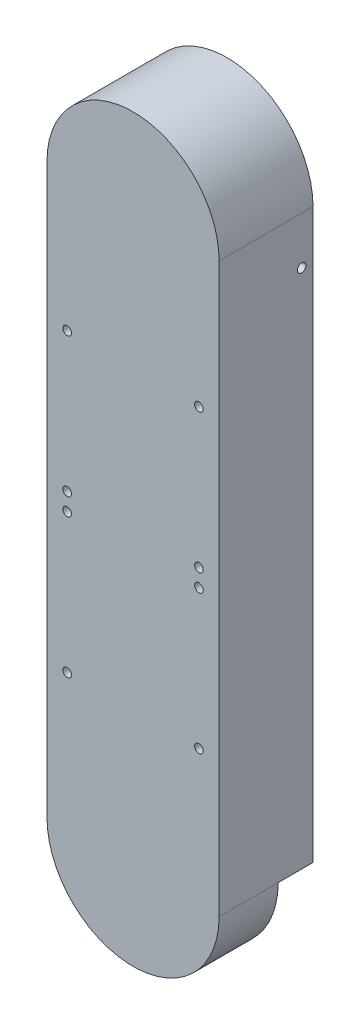
from build123d import *

# Parameters (mm, degrees)
EXTRUDE_1_DEPTH     = 35
EXTRUDE_2_DEPTH     = 3.18
SKETCH_3_R          = 1.75
CUT_EXTRUDE_1_DEPTH = 39.18
SKETCH_4_R          = 1.75
CUT_EXTRUDE_2_DEPTH = 39.18
SKETCH_5_R          = 1.75
CUT_EXTRUDE_3_DEPTH = 71
EXTRUDE_3_DEPTH     = 115.49
EXTRUDE_7_DEPTH     = 24
SKETCH_11_R         = 25
CUT_EXTRUDE_4_DEPTH = 20.82
SKETCH_12_R         = 1.75
CUT_EXTRUDE_5_DEPTH = 39.18
SKETCH_13_R         = 1.75
CUT_EXTRUDE_6_DEPTH = 24


with BuildPart() as part:
    # 草图1 → 凸台-拉伸1 (new body)
    with BuildSketch(Plane.XY):
        with BuildLine():
            Line((-30, 0), (-30, -115.49))
            Line((-30, -115.49), (-35, -115.49))
            Line((-35, -115.49), (-35, 0))
            ThreePointArc((-35, 0), (0, 35), (35, 0))
            Line((35, 0), (35, -115.49))
            Line((35, -115.49), (30, -115.49))
            Line((30, -115.49), (30, 0))
            ThreePointArc((30, 0), (0, 30), (-30, 0))
        make_face()
    extrude(amount=EXTRUDE_1_DEPTH)

    # 草图2 → 凸台-拉伸2 (add)
    with BuildSketch(Plane.XY.offset(35)):
        with BuildLine():
            Line((-30, -115.49), (30, -115.49))
            Line((30, -115.49), (35, -115.49))
            Line((35, -115.49), (35, 0))
            ThreePointArc((35, 0), (0, 35), (-35, 0))
            Line((-35, 0), (-35, -115.49))
            Line((-35, -115.49), (-30, -115.49))
        make_face()
    extrude(amount=EXTRUDE_2_DEPTH)

    # 草图3 → 切除-拉伸1 (cut, through all)
    with BuildSketch(Plane(origin=(0, 0, 0), x_dir=(-1, 0, 0), z_dir=(0, 0, -1))):
        with Locations((-26.795, -112.09)):
            Circle(SKETCH_3_R)
        with Locations((26.795, -112.09)):
            Circle(SKETCH_3_R)
    extrude(amount=-CUT_EXTRUDE_1_DEPTH, mode=Mode.SUBTRACT)

    # 草图4 → 切除-拉伸2 (cut, through all)
    with BuildSketch(Plane(origin=(0, 0, 0), x_dir=(-1, 0, 0), z_dir=(0, 0, -1))):
        with Locations((-26.795, -55.49)):
            Circle(SKETCH_4_R)
        with Locations((26.795, -55.49)):
            Circle(SKETCH_4_R)
    extrude(amount=-CUT_EXTRUDE_2_DEPTH, mode=Mode.SUBTRACT)

    # 草图5 → 切除-拉伸3 (cut, through all)
    with BuildSketch(Plane(origin=(35, 0, 0), x_dir=(0, 0, -1), z_dir=(1, 0, 0))):
        with Locations((-4.61, -19.28)):
            Circle(SKETCH_5_R)
    extrude(amount=-CUT_EXTRUDE_3_DEPTH, mode=Mode.SUBTRACT)

    # 草图6 → 凸台-拉伸3 (add)
    with BuildSketch(Plane.XZ.offset(115.49)):
        Polygon((30, 0), (35, 0), (35, 38.18), (-35, 38.18), (-35, 0), (-30, 0), (-30, 35), (30, 35), align=None)
    extrude(amount=EXTRUDE_3_DEPTH)

    # 草图10 → 凸台-拉伸7 (add)
    with BuildSketch(Plane.XY.offset(38.18)):
        with BuildLine():
            Line((35, -230.98), (-35, -230.98))
            ThreePointArc((-35, -230.98), (0, -265.98), (35, -230.98))
        make_face()
    extrude(amount=-EXTRUDE_7_DEPTH)

    # 草图11 → 切除-拉伸4 (cut)
    with BuildSketch(Plane(origin=(0, 0, 14.18), x_dir=(-1, 0, 0), z_dir=(0, 0, -1))):
        with Locations((0, -230.98)):
            Circle(SKETCH_11_R)
    extrude(amount=-CUT_EXTRUDE_4_DEPTH, mode=Mode.SUBTRACT)

    # 草图12 → 切除-拉伸5 (cut, through all)
    with BuildSketch(Plane.XY.offset(38.18)):
        with Locations((26.795, -119.23)):
            Circle(SKETCH_12_R)
        with Locations((-26.795, -119.23)):
            Circle(SKETCH_12_R)
    extrude(amount=-CUT_EXTRUDE_5_DEPTH, mode=Mode.SUBTRACT)

    # 草图13 → 切除-拉伸6 (cut)
    with BuildSketch(Plane.XY.offset(38.18)):
        with Locations((-26.795, -175.86)):
            Circle(SKETCH_13_R)
        with Locations((26.795, -175.86)):
            Circle(SKETCH_13_R)
    extrude(amount=-CUT_EXTRUDE_6_DEPTH, mode=Mode.SUBTRACT)


solid = part.part
